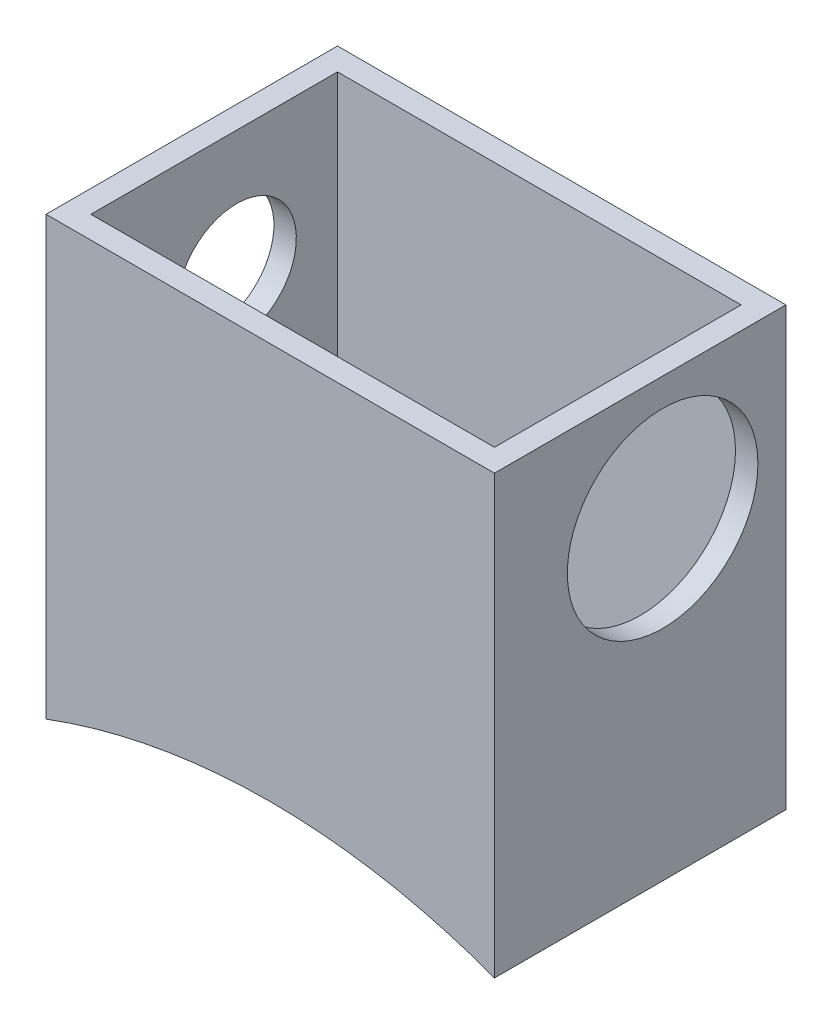
from build123d import *

# Parameters (mm, degrees)
BOSS_EXTRUDE1_DEPTH       = 5.588
F_6_32_TAPPED_HOLE1_D     = 2.7051
F_6_32_TAPPED_HOLE1_DEPTH = 0.508
CUT_EXTRUDE1_REACH        = 12.16
SKETCH6_R                 = 2.159
CUT_EXTRUDE2_DEPTH        = 6.588
BOSS_EXTRUDE3_DEPTH       = 1.016
SKETCH20_W                = 9.144
SKETCH20_H                = 2.56692539
CUT_EXTRUDE3_DEPTH        = 8.382
SKETCH22_W                = 9.144
SKETCH22_H                = 8.382
BOSS_EXTRUDE4_DEPTH       = 0.508
SKETCH24_W                = 9.144
SKETCH24_H                = 8.382
BOSS_EXTRUDE5_DEPTH       = 0.508


with BuildPart() as part:
    # Sketch1 → Boss-Extrude1 (new body)
    with BuildSketch(Plane.XY):
        Polygon((-3.353873239, 7.634688699), (-3.353873239, -2.271311301), (6.806126761, -2.271311301), (6.806126761, 7.634688699), (6.298126761, 7.634688699), (6.298126761, -0.747311301), (-2.845873239, -0.747311301), (-2.845873239, 7.634688699), align=None)
    extrude(amount=BOSS_EXTRUDE1_DEPTH)

    # #6-32 Tapped Hole1
    with Locations(Plane.ZY.offset(3.353873239)):
        with Locations((2.794, 4.840688699)):
            Hole(F_6_32_TAPPED_HOLE1_D / 2, depth=F_6_32_TAPPED_HOLE1_DEPTH)

    # Sketch6 → Cut-Extrude1 (cut, up to next)
    with BuildSketch(Plane(origin=(6.806126761, 0, 0), x_dir=(0, 0, -1), z_dir=(1, 0, 0)), mode=Mode.PRIVATE) as cut_extrude1_sk1:
        with Locations((-2.794, 4.840688699)):
            Circle(SKETCH6_R)
    cut_extrude1_tool1 = extrude(cut_extrude1_sk1.sketch, amount=-CUT_EXTRUDE1_REACH, mode=Mode.PRIVATE) & part.part
    add(cut_extrude1_tool1.solids().sort_by_distance((6.806127, 4.840689, 2.794))[0], mode=Mode.SUBTRACT)

    # Sketch16 → Cut-Extrude2 (cut, through all)
    with BuildSketch(Plane(origin=(0, 0, 0), x_dir=(-1, 0, 0), z_dir=(0, 0, -1))):
        with BuildLine():
            Line((3.353873239, -2.271311301), (-6.806126761, -2.271311301))
            ThreePointArc((-6.806126761, -2.271311301), (-1.726126761, -1.350821544), (3.353873239, -2.271311301))
        make_face()
    extrude(amount=-CUT_EXTRUDE2_DEPTH, mode=Mode.SUBTRACT)

    # Sketch19 → Boss-Extrude3 (add)
    with BuildSketch(Plane.XY.offset(5.588)):
        with BuildLine():
            Line((6.806126761, 7.634688699), (6.298126761, 7.634688699))
            Line((6.298126761, 7.634688699), (-2.845873239, 7.634688699))
            Line((-2.845873239, 7.634688699), (-3.353873239, 7.634688699))
            Line((-3.353873239, 7.634688699), (-3.353873239, -2.271311301))
            ThreePointArc((-3.353873239, -2.271311301), (1.726126761, -1.350821544), (6.806126761, -2.271311301))
            Line((6.806126761, -2.271311301), (6.806126761, 7.634688699))
        make_face()
    extrude(amount=BOSS_EXTRUDE3_DEPTH)

    # Sketch20 → Cut-Extrude3 (cut)
    with BuildSketch(Plane(origin=(0, 7.634688699, 0), x_dir=(1, 0, 0), z_dir=(0, 1, 0))):
        with Locations((1.726126761, -6.871462695)):
            Rectangle(SKETCH20_W, SKETCH20_H)
    extrude(amount=-CUT_EXTRUDE3_DEPTH, mode=Mode.SUBTRACT)

    # Sketch22 → Boss-Extrude4 (add)
    with BuildSketch(Plane.XY.offset(6.604)):
        with Locations((1.726126761, 3.443688699)):
            Rectangle(SKETCH22_W, SKETCH22_H)
    extrude(amount=-BOSS_EXTRUDE4_DEPTH)

    # Sketch24 → Boss-Extrude5 (add)
    with BuildSketch(Plane(origin=(0, 0, 0), x_dir=(-1, 0, 0), z_dir=(0, 0, -1))):
        with Locations((-1.726126761, 3.443688699)):
            Rectangle(SKETCH24_W, SKETCH24_H)
    extrude(amount=-BOSS_EXTRUDE5_DEPTH)


solid = part.part
